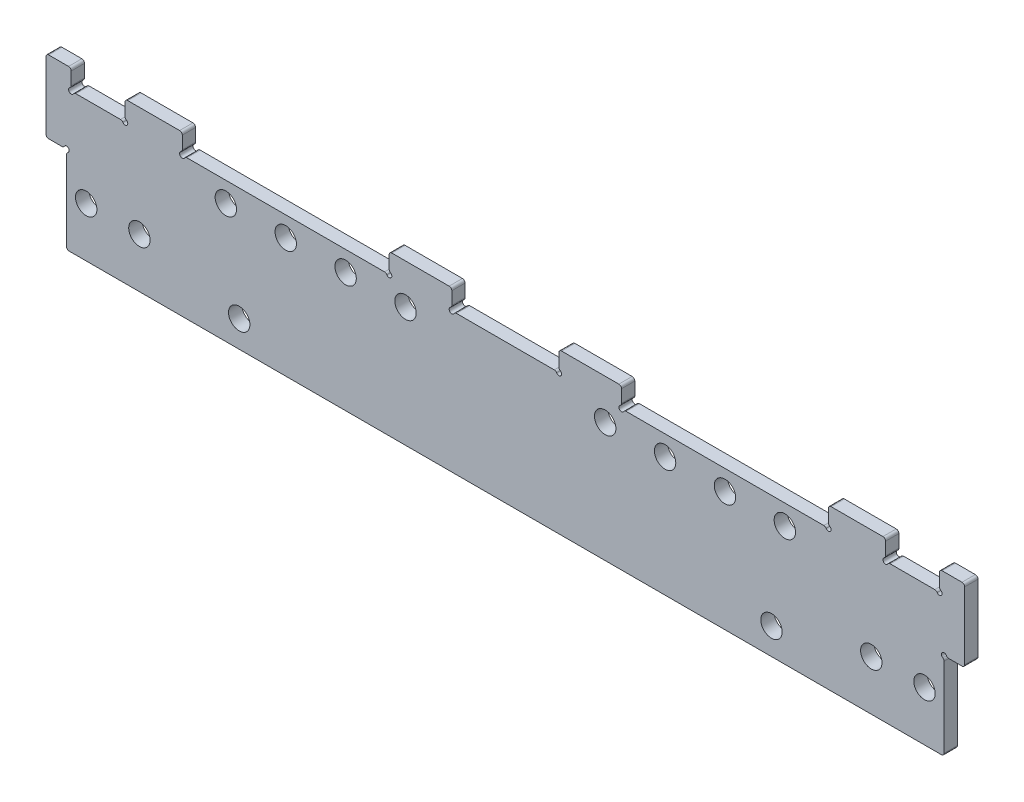
from build123d import *

# Parameters (mm, degrees)
SKETCH41_R                  = 2.5527
BACK_PLATE_EXTRUDE_DEPTH    = 3.175
SKETCH71_W                  = 8.89
SKETCH71_H                  = 4.7625
SKETCH71_W_2                = 13.79855
SKETCH71_W_3                = 15.09395
BOSS_EXTRUDE26_DEPTH        = 3.175
SKETCH91_W                  = 4.9022
SKETCH91_H                  = 20.7645
SKETCH91_W_2                = 12.8524
SKETCH91_H_2                = 4.7625
SKETCH91_W_3                = 49.3649
SKETCH91_W_4                = 12.7762
BACK_PLATE_TOLERENCES_DEPTH = 4.175
SKETCH92_W                  = 2.794
SKETCH92_H                  = 26.9875
CUT_EXTRUDE1_DEPTH          = 4.175
FILLET27_R                  = 0.635
FILLET28_R                  = 0.635
SKETCH93_R                  = 0.635
CUT_EXTRUDE2_DEPTH          = 4.175
FILLET29_R                  = 0.635
FILLET29_OF_MIRROR26_R      = 0.635


with BuildPart() as part:
    # Sketch41 → Back Plate Extrude------------ (new body)
    with BuildSketch(Plane.XY.offset(152.527)):
        Polygon((-104.775, -7.9375), (-104.775, 12.7), (-109.5248, 12.7), (-109.5248, 3.175), (-112.395, 3.175), (-112.395, 25.4), (-104.775, 25.4), (104.775, 25.4), (112.395, 25.4), (112.395, 3.175), (109.5248, 3.175), (109.5248, 12.7), (104.775, 12.7), (104.775, -7.9375), align=None)
        with Locations((-100.0125, 3.9624)):
            Circle(SKETCH41_R, mode=Mode.SUBTRACT)
        with Locations((100.0125, 3.9624)):
            Circle(SKETCH41_R, mode=Mode.SUBTRACT)
        with Locations((23.8252, 20.6375)):
            Circle(SKETCH41_R, mode=Mode.SUBTRACT)
        with Locations((38.1127, 20.6375)):
            Circle(SKETCH41_R, mode=Mode.SUBTRACT)
        with Locations((52.4002, 20.6375)):
            Circle(SKETCH41_R, mode=Mode.SUBTRACT)
        with Locations((66.6877, 20.6375)):
            Circle(SKETCH41_R, mode=Mode.SUBTRACT)
        with Locations((-66.6877, 20.6375)):
            Circle(SKETCH41_R, mode=Mode.SUBTRACT)
        with Locations((-52.4002, 20.6375)):
            Circle(SKETCH41_R, mode=Mode.SUBTRACT)
        with Locations((-38.1127, 20.6375)):
            Circle(SKETCH41_R, mode=Mode.SUBTRACT)
        with Locations((-23.8252, 20.6375)):
            Circle(SKETCH41_R, mode=Mode.SUBTRACT)
        with Locations((-87.3125, 3.9624)):
            Circle(SKETCH41_R, mode=Mode.SUBTRACT)
        with Locations((87.3125, 3.9624)):
            Circle(SKETCH41_R, mode=Mode.SUBTRACT)
        with Locations((-63.5, -1.5875)):
            Circle(SKETCH41_R, mode=Mode.SUBTRACT)
        with Locations((63.5, -1.5875)):
            Circle(SKETCH41_R, mode=Mode.SUBTRACT)
    extrude(amount=BACK_PLATE_EXTRUDE_DEPTH)

    # Sketch71 → Boss-Extrude26 (add, through all)
    with BuildSketch(Plane.XY.offset(155.702)):
        with Locations((-107.95, 27.78125)):
            Rectangle(SKETCH71_W, SKETCH71_H)
        with Locations((-83.905725, 27.78125)):
            Rectangle(SKETCH71_W_2, SKETCH71_H)
        with Locations((-20.246975, 27.78125)):
            Rectangle(SKETCH71_W_3, SKETCH71_H)
    boss_extrude26 = extrude(amount=-BOSS_EXTRUDE26_DEPTH)

    # Mirror23: Boss-Extrude26 across plane
    add(boss_extrude26.mirror(Plane(origin=(0, 0, 0), x_dir=(0, 0, 1), z_dir=(1, 0, 0))))

    # Sketch91 → Back Plate Tolerences (cut, through all)
    with BuildSketch(Plane(origin=(0, 0, 152.527), x_dir=(-1, 0, 0), z_dir=(0, 0, -1))):
        with Locations((-107.1499, 2.44475)):
            Rectangle(SKETCH91_W, SKETCH91_H)
        with Locations((-97.155, 27.78125)):
            Rectangle(SKETCH91_W_2, SKETCH91_H_2)
        with Locations((-52.4002, 27.78125)):
            Rectangle(SKETCH91_W_3, SKETCH91_H_2)
        with Locations((-6.3881, 27.78125)):
            Rectangle(SKETCH91_W_4, SKETCH91_H_2)
    back_plate_tolerences = extrude(amount=-BACK_PLATE_TOLERENCES_DEPTH, mode=Mode.SUBTRACT)

    # Mirror25: Back Plate Tolerences across plane
    add(back_plate_tolerences.mirror(Plane(origin=(0, 0, 0), x_dir=(0, 0, 1), z_dir=(1, 0, 0))), mode=Mode.SUBTRACT)

    # Sketch92 → Cut-Extrude1 (cut, through all)
    with BuildSketch(Plane.XY.offset(155.702)):
        with Locations((-110.998, 16.66875)):
            Rectangle(SKETCH92_W, SKETCH92_H)
        with Locations((110.998, 16.66875)):
            Rectangle(SKETCH92_W, SKETCH92_H)
    extrude(amount=-CUT_EXTRUDE1_DEPTH, mode=Mode.SUBTRACT)

    # Fillet27
    fillet27_edges = [part.edges().sort_by_distance(p)[0] for p in [
        (104.6988, -7.9375, 154.1145),
        (109.601, 12.827, 154.1145),
        (-109.601, 12.827, 154.1145),
        (-104.6988, -7.9375, 154.1145),
        (-109.601, 30.1625, 154.1145),
        (109.601, 30.1625, 154.1145),
    ]]
    fillet(fillet27_edges, radius=FILLET27_R)

    # Fillet28
    fillet28_edges = [part.edges().sort_by_distance(p)[0] for p in [
        (103.5812, 30.1625, 154.1145),
        (90.7288, 30.1625, 154.1145),
        (77.08265, 30.1625, 154.1145),
        (27.71775, 30.1625, 154.1145),
        (12.7762, 30.1625, 154.1145),
        (-103.5812, 30.1625, 154.1145),
        (-90.7288, 30.1625, 154.1145),
        (-27.71775, 30.1625, 154.1145),
        (-77.08265, 30.1625, 154.1145),
        (-12.7762, 30.1625, 154.1145),
    ]]
    fillet(fillet28_edges, radius=FILLET28_R)

    # Sketch93 → Cut-Extrude2 (cut, through all)
    with BuildSketch(Plane.XY.offset(155.702)):
        with Locations((-104.6988, 12.827)):
            Circle(SKETCH93_R)
        with Locations((-103.5812, 25.4)):
            Circle(SKETCH93_R)
        with Locations((-90.7288, 25.4)):
            Circle(SKETCH93_R)
        with Locations((-77.08265, 25.4)):
            Circle(SKETCH93_R)
        with Locations((-27.71775, 25.4)):
            Circle(SKETCH93_R)
        with Locations((-12.7762, 25.4)):
            Circle(SKETCH93_R)
    cut_extrude2 = extrude(amount=-CUT_EXTRUDE2_DEPTH, mode=Mode.SUBTRACT)

    # Fillet29
    fillet29_edges = [part.edges().sort_by_distance(p)[0] for p in [
        (-105.3338, 12.827, 154.1145),
        (-103.5812, 26.035, 154.1145),
        (-27.71775, 26.035, 154.1145),
        (-12.7762, 26.035, 154.1145),
        (-90.7288, 26.035, 154.1145),
        (-77.08265, 26.035, 154.1145),
        (-104.6988, 12.192, 154.1145),
        (-102.9462, 25.4, 154.1145),
        (-91.3638, 25.4, 154.1145),
        (-76.44765, 25.4, 154.1145),
        (-28.35275, 25.4, 154.1145),
        (-12.1412, 25.4, 154.1145),
    ]]
    fillet(fillet29_edges, radius=FILLET29_R)

    # Mirror26: Cut-Extrude2 across plane
    add(cut_extrude2.mirror(Plane(origin=(0, 0, 0), x_dir=(0, 0, 1), z_dir=(1, 0, 0))), mode=Mode.SUBTRACT)

    # Fillet29 of Mirror26
    fillet29_of_mirror26_edges = [part.edges().sort_by_distance(p)[0] for p in [
        (105.3338, 12.827, 154.1145),
        (103.5812, 26.035, 154.1145),
        (27.71775, 26.035, 154.1145),
        (12.7762, 26.035, 154.1145),
        (90.7288, 26.035, 154.1145),
        (77.08265, 26.035, 154.1145),
        (104.6988, 12.192, 154.1145),
        (102.9462, 25.4, 154.1145),
        (91.3638, 25.4, 154.1145),
        (76.44765, 25.4, 154.1145),
        (28.35275, 25.4, 154.1145),
        (12.1412, 25.4, 154.1145),
    ]]
    fillet(fillet29_of_mirror26_edges, radius=FILLET29_OF_MIRROR26_R)


solid = part.part
